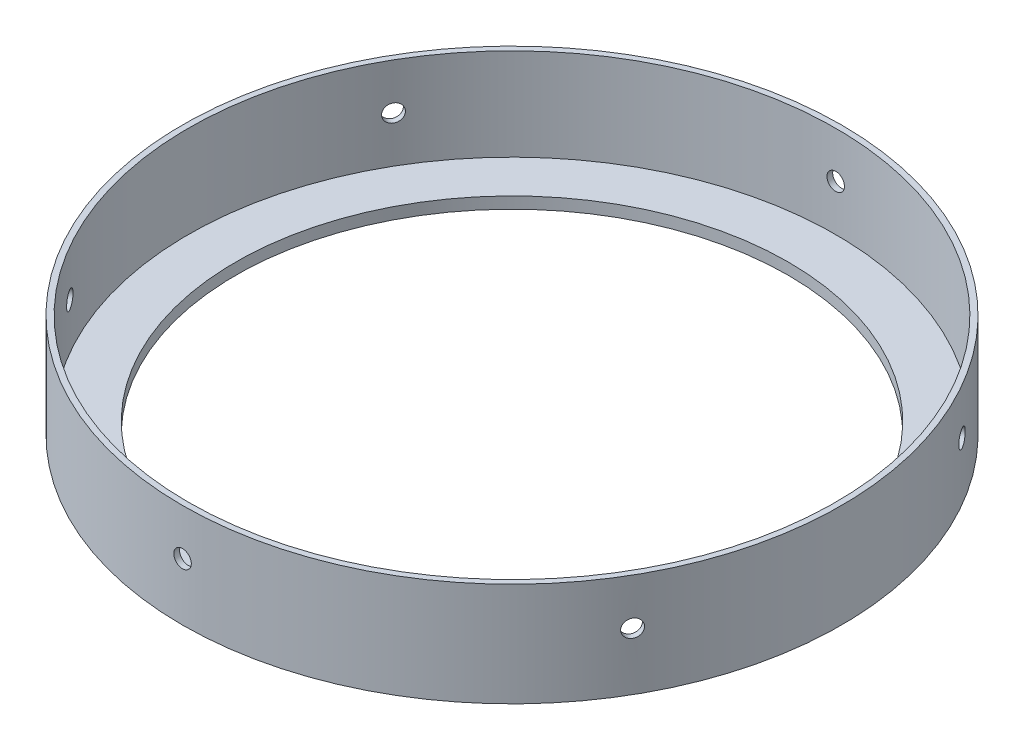
from build123d import *

# Parameters (mm, degrees)
SKETCH1_R           = 90.884375
BOSS_EXTRUDE1_DEPTH = 28.575
SKETCH2_R           = 89.296875
CUT_EXTRUDE1_DEPTH  = 25.4
SKETCH3_R           = 76.2
CUT_EXTRUDE2_DEPTH  = 4.175
SKETCH4_R           = 2.413
CUT_EXTRUDE3_DEPTH  = 91.884375
CIRPATTERN1_COUNT   = 6


with BuildPart() as part:
    # Sketch1 → Boss-Extrude1 (new body)
    with BuildSketch(Plane(origin=(0, 0, 0), x_dir=(1, 0, 0), z_dir=(0, 1, 0))):
        Circle(SKETCH1_R)
    extrude(amount=BOSS_EXTRUDE1_DEPTH)

    # Sketch2 → Cut-Extrude1 (cut)
    with BuildSketch(Plane(origin=(0, 28.575, 0), x_dir=(1, 0, 0), z_dir=(0, 1, 0))):
        Circle(SKETCH2_R)
    extrude(amount=-CUT_EXTRUDE1_DEPTH, mode=Mode.SUBTRACT)

    # Sketch3 → Cut-Extrude2 (cut, through all)
    with BuildSketch(Plane(origin=(0, 3.175, 0), x_dir=(1, 0, 0), z_dir=(0, 1, 0))):
        Circle(SKETCH3_R)
    extrude(amount=-CUT_EXTRUDE2_DEPTH, mode=Mode.SUBTRACT)

    # Sketch4 → Cut-Extrude3 (cut, symmetric)
    with BuildSketch(Plane.XY):
        with Locations((0, 15.875)):
            Circle(SKETCH4_R)
    cut_extrude3 = extrude(amount=CUT_EXTRUDE3_DEPTH, both=True, mode=Mode.SUBTRACT)

    # CirPattern1: Cut-Extrude3 ×6 about axis
    cirpattern1_axis = Axis((0, 28.575, 0), (0, 1, 0))
    for i in range(1, CIRPATTERN1_COUNT):
        add(cut_extrude3.rotate(cirpattern1_axis, i * 360 / CIRPATTERN1_COUNT), mode=Mode.SUBTRACT)


solid = part.part
